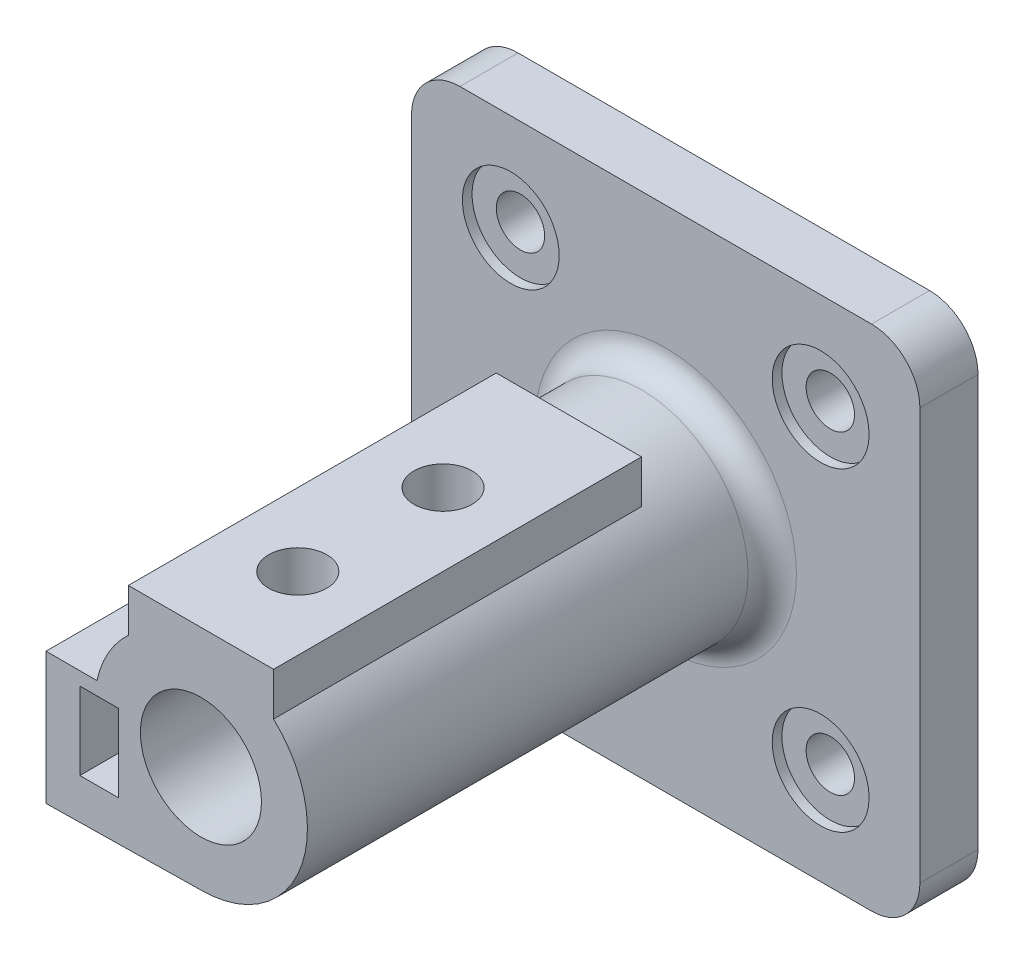
from build123d import *

# Parameters (mm, degrees)
SKETCH1_W               = 105
SKETCH1_H               = 105
BOSS_EXTRUDE1_DEPTH     = 12
SKETCH2_R               = 22
SKETCH2_R_2             = 12.5
BOSS_EXTRUDE2_DEPTH     = 96
FILLET1_R               = 5
SKETCH4_R               = 10
CUT_EXTRUDE2_DEPTH      = 2
SKETCH6_R               = 5
CUT_EXTRUDE3_DEPTH      = 11
MIRROR3_COPY_1_SKETCH_R = 10
MIRROR3_COPY_1_DEPTH    = 2
MIRROR3_COPY_2_SKETCH_R = 5
MIRROR3_COPY_2_DEPTH    = 11
BOSS_EXTRUDE5_DEPTH     = 57
SKETCH9_W               = 8
SKETCH9_H               = 16
CUT_EXTRUDE5_DEPTH      = 50
BOSS_EXTRUDE6_DEPTH     = 76
CUT_EXTRUDE6_REACH      = 79.5
SKETCH11_R              = 6
FILLET2_R               = 10
CUT_EXTRUDE7_REACH      = 86.5
SKETCH12_R              = 5


with BuildPart() as part:
    # Sketch1 → Boss-Extrude1 (new body)
    with BuildSketch(Plane.XY):
        Rectangle(SKETCH1_W, SKETCH1_H)
    extrude(amount=BOSS_EXTRUDE1_DEPTH)

    # Sketch2 → Boss-Extrude2 (add)
    with BuildSketch(Plane.XY.offset(12)):
        Circle(SKETCH2_R)
        Circle(SKETCH2_R_2, mode=Mode.SUBTRACT)
    extrude(amount=BOSS_EXTRUDE2_DEPTH)

    # Fillet1
    fillet1_edges = [part.edges().sort_by_distance(p)[0] for p in [
        (-22, 0, 12),
    ]]
    fillet(fillet1_edges, radius=FILLET1_R)

    # Sketch4 → Cut-Extrude2 (cut)
    with BuildSketch(Plane.XY.offset(12)):
        with Locations((-32, 32.5)):
            Circle(SKETCH4_R)
    cut_extrude2 = extrude(amount=-CUT_EXTRUDE2_DEPTH, mode=Mode.SUBTRACT)

    # Sketch6 → Cut-Extrude3 (cut, through all)
    with BuildSketch(Plane.XY.offset(10)):
        with Locations((-32, 32.5)):
            Circle(SKETCH6_R)
    cut_extrude3 = extrude(amount=-CUT_EXTRUDE3_DEPTH, mode=Mode.SUBTRACT)

    # Mirror2: Cut-Extrude2, Cut-Extrude3 across plane
    add(cut_extrude2.mirror(Plane(origin=(0, 0, 0), x_dir=(0, 0, 1), z_dir=(1, 0, 0))), mode=Mode.SUBTRACT)
    add(cut_extrude3.mirror(Plane(origin=(0, 0, 0), x_dir=(0, 0, 1), z_dir=(1, 0, 0))), mode=Mode.SUBTRACT)

    # Mirror3: Cut-Extrude3, Cut-Extrude2 across plane
    add(cut_extrude3.mirror(Plane.ZX), mode=Mode.SUBTRACT)
    add(cut_extrude2.mirror(Plane.ZX), mode=Mode.SUBTRACT)

    # Mirror3 copy 1 sketch → Mirror3 copy 1 (cut)
    with BuildSketch(Plane(origin=(0, 0, 12), x_dir=(-1, 0, 0), z_dir=(0, 0, 1))):
        with Locations((-32, 32.5)):
            Circle(MIRROR3_COPY_1_SKETCH_R)
    extrude(amount=-MIRROR3_COPY_1_DEPTH, mode=Mode.SUBTRACT)

    # Mirror3 copy 2 sketch → Mirror3 copy 2 (cut, through all)
    with BuildSketch(Plane(origin=(0, 0, 10), x_dir=(-1, 0, 0), z_dir=(0, 0, 1))):
        with Locations((-32, 32.5)):
            Circle(MIRROR3_COPY_2_SKETCH_R)
    extrude(amount=-MIRROR3_COPY_2_DEPTH, mode=Mode.SUBTRACT)

    # Sketch8 → Boss-Extrude5 (add)
    with BuildSketch(Plane.XY.offset(108)):
        with BuildLine():
            Line((-32, -22.5), (0, -22))
            ThreePointArc((0, -22), (-9.401774275, -19.889862757), (-17, -13.964240044))
            Line((-17, -13.964240044), (-17, -14))
            Line((-17, -14), (-25, -14))
            Line((-25, -14), (-25, 2))
            Line((-25, 2), (-21.9089023, 2))
            ThreePointArc((-21.9089023, 2), (-21.739374416, 3.37632937), (-21.483471943, 4.739243954))
            Line((-21.483471943, 4.739243954), (-32, 4.739243954))
            Line((-32, 4.739243954), (-32, -22.5))
        make_face()
    extrude(amount=-BOSS_EXTRUDE5_DEPTH)

    # Sketch9 → Cut-Extrude5 (cut)
    with BuildSketch(Plane.XY.offset(108)):
        with Locations((-21, -6)):
            Rectangle(SKETCH9_W, SKETCH9_H)
    extrude(amount=-CUT_EXTRUDE5_DEPTH, mode=Mode.SUBTRACT)

    # Sketch10 → Boss-Extrude6 (add)
    with BuildSketch(Plane.XY.offset(108)):
        with BuildLine():
            Line((-15, 25), (15, 25))
            Line((15, 25), (15, 16.093476939))
            ThreePointArc((15, 16.093476939), (0, 22), (-15, 16.093476939))
            Line((-15, 16.093476939), (-15, 25))
        make_face()
    extrude(amount=-BOSS_EXTRUDE6_DEPTH)

    # Sketch11 → Cut-Extrude6 (cut, up to next)
    with BuildSketch(Plane(origin=(0, 25, 0), x_dir=(1, 0, 0), z_dir=(0, 1, 0)), mode=Mode.PRIVATE) as cut_extrude6_sk1:
        with Locations((0, -88)):
            Circle(SKETCH11_R)
    cut_extrude6_tool1 = extrude(cut_extrude6_sk1.sketch, amount=-CUT_EXTRUDE6_REACH, mode=Mode.PRIVATE) & part.part
    add(cut_extrude6_tool1.solids().sort_by_distance((0, 25, 88))[0], mode=Mode.SUBTRACT)
    # Sketch11 → Cut-Extrude6 (cut, up to next)
    with BuildSketch(Plane(origin=(0, 25, 0), x_dir=(1, 0, 0), z_dir=(0, 1, 0)), mode=Mode.PRIVATE) as cut_extrude6_sk2:
        with Locations((0, -58)):
            Circle(SKETCH11_R)
    cut_extrude6_tool2 = extrude(cut_extrude6_sk2.sketch, amount=-CUT_EXTRUDE6_REACH, mode=Mode.PRIVATE) & part.part
    add(cut_extrude6_tool2.solids().sort_by_distance((0, 25, 58))[0], mode=Mode.SUBTRACT)

    # Fillet2
    fillet2_edges = [part.edges().sort_by_distance(p)[0] for p in [
        (52.5, -52.5, 6),
        (-52.5, -52.5, 6),
        (-52.5, 52.5, 6),
        (52.5, 52.5, 6),
    ]]
    fillet(fillet2_edges, radius=FILLET2_R)

    # Sketch12 → Cut-Extrude7 (cut, up to next)
    with BuildSketch(Plane.ZY.offset(32), mode=Mode.PRIVATE) as cut_extrude7_sk1:
        with Locations((93, -8.880378023)):
            Circle(SKETCH12_R)
    cut_extrude7_tool1 = extrude(cut_extrude7_sk1.sketch, amount=-CUT_EXTRUDE7_REACH, mode=Mode.PRIVATE) & part.part
    add(cut_extrude7_tool1.solids().sort_by_distance((-32, -8.880378, 93))[0], mode=Mode.SUBTRACT)
    # Sketch12 → Cut-Extrude7 (cut, up to next)
    with BuildSketch(Plane.ZY.offset(32), mode=Mode.PRIVATE) as cut_extrude7_sk2:
        with Locations((71, -8.880378023)):
            Circle(SKETCH12_R)
    cut_extrude7_tool2 = extrude(cut_extrude7_sk2.sketch, amount=-CUT_EXTRUDE7_REACH, mode=Mode.PRIVATE) & part.part
    add(cut_extrude7_tool2.solids().sort_by_distance((-32, -8.880378, 71))[0], mode=Mode.SUBTRACT)


solid = part.part
